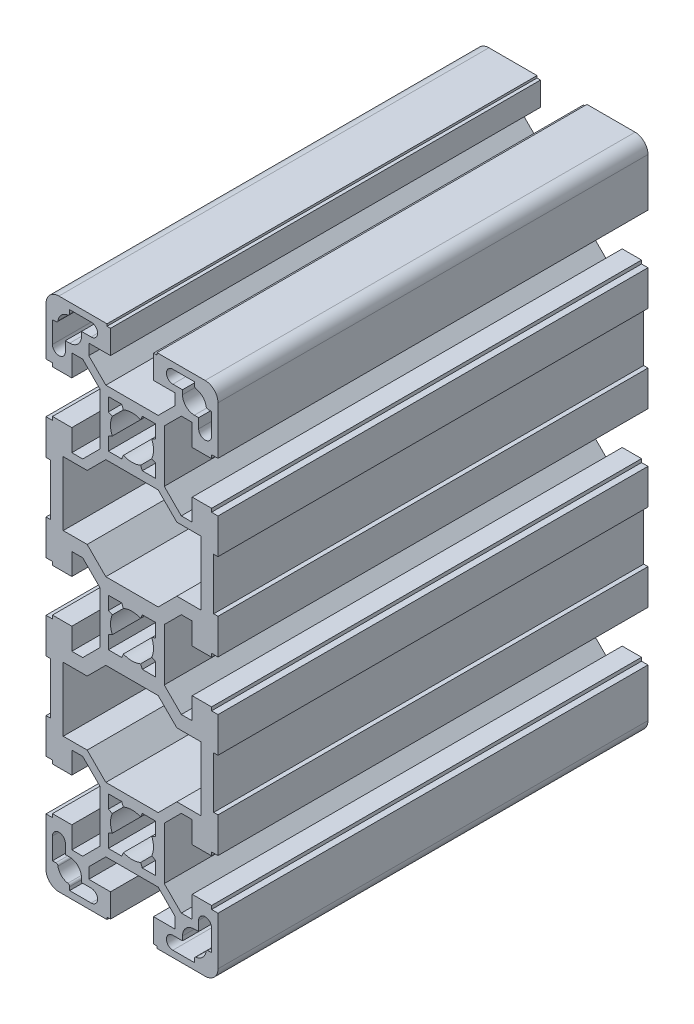
from build123d import *

# Parameters (mm, degrees)
EXTRUDE1_DEPTH = 100


with BuildPart() as part:
    # Sketch1 → Extrude1 (new body)
    with BuildSketch(Plane.XY):
        with BuildLine():
            Line((20, -57), (20, -45.8))
            Line((20, -45.8), (18.5, -45.8))
            Line((18.5, -45.8), (18.5, -45))
            Line((18.5, -45), (14, -45))
            Line((14, -45), (14, -50.05))
            Line((14, -50.05), (11.464213562, -50.05))
            Line((11.464213562, -50.05), (7.5, -46.085786438))
            Line((7.5, -46.085786438), (7.5, -33.914213562))
            Line((7.5, -33.914213562), (11.464213562, -29.95))
            Line((11.464213562, -29.95), (14, -29.95))
            Line((14, -29.95), (14, -35))
            Line((14, -35), (18.5, -35))
            Line((18.5, -35), (18.5, -34.2))
            Line((18.5, -34.2), (20, -34.2))
            Line((20, -34.2), (20, -26))
            Line((20, -26), (19, -26))
            Line((19, -26), (19, -14))
            Line((19, -14), (20, -14))
            Line((20, -14), (20, -5.8))
            Line((20, -5.8), (18.5, -5.8))
            Line((18.5, -5.8), (18.5, -5))
            Line((18.5, -5), (14, -5))
            Line((14, -5), (14, -10.05))
            Line((14, -10.05), (11.464213562, -10.05))
            Line((11.464213562, -10.05), (7.5, -6.085786438))
            Line((7.5, -6.085786438), (7.5, 6.085786438))
            Line((7.5, 6.085786438), (11.464213562, 10.05))
            Line((11.464213562, 10.05), (14, 10.05))
            Line((14, 10.05), (14, 5))
            Line((14, 5), (18.5, 5))
            Line((18.5, 5), (18.5, 5.8))
            Line((18.5, 5.8), (20, 5.8))
            Line((20, 5.8), (20, 14))
            Line((20, 14), (19, 14))
            Line((19, 14), (19, 26))
            Line((19, 26), (20, 26))
            Line((20, 26), (20, 34.2))
            Line((20, 34.2), (18.5, 34.2))
            Line((18.5, 34.2), (18.5, 35))
            Line((18.5, 35), (14, 35))
            Line((14, 35), (14, 29.95))
            Line((14, 29.95), (11.464213562, 29.95))
            Line((11.464213562, 29.95), (7.5, 33.914213562))
            Line((7.5, 33.914213562), (7.5, 46.085786438))
            Line((7.5, 46.085786438), (11.464213562, 50.05))
            Line((11.464213562, 50.05), (14, 50.05))
            Line((14, 50.05), (14, 45))
            Line((14, 45), (18.5, 45))
            Line((18.5, 45), (18.5, 45.8))
            Line((18.5, 45.8), (20, 45.8))
            Line((20, 45.8), (20, 57))
            ThreePointArc((20, 57), (19.121320344, 59.121320344), (17, 60))
            Line((17, 60), (5.805149148, 60))
            Line((5.805149148, 60), (5.805149148, 59.5))
            Line((5.805149148, 59.5), (5, 59.5))
            Line((5, 59.5), (5, 54))
            Line((5, 54), (10.05, 54))
            Line((10.05, 54), (10.05, 51.464213562))
            Line((10.05, 51.464213562), (6.085786438, 47.5))
            Line((6.085786438, 47.5), (-6.085786438, 47.5))
            Line((-6.085786438, 47.5), (-10.05, 51.464213562))
            Line((-10.05, 51.464213562), (-10.05, 54))
            Line((-10.05, 54), (-5, 54))
            Line((-5, 54), (-5, 59.5))
            Line((-5, 59.5), (-5.805149148, 59.5))
            Line((-5.805149148, 59.5), (-5.805149148, 60))
            Line((-5.805149148, 60), (-17, 60))
            ThreePointArc((-17, 60), (-19.121320344, 59.121320344), (-20, 57))
            Line((-20, 57), (-20, 45.8))
            Line((-20, 45.8), (-18.5, 45.8))
            Line((-18.5, 45.8), (-18.5, 45))
            Line((-18.5, 45), (-14, 45))
            Line((-14, 45), (-14, 50.05))
            Line((-14, 50.05), (-11.464213562, 50.05))
            Line((-11.464213562, 50.05), (-7.5, 46.085786438))
            Line((-7.5, 46.085786438), (-7.5, 33.914213562))
            Line((-7.5, 33.914213562), (-11.464213562, 29.95))
            Line((-11.464213562, 29.95), (-14, 29.95))
            Line((-14, 29.95), (-14, 35))
            Line((-14, 35), (-18.5, 35))
            Line((-18.5, 35), (-18.5, 34.2))
            Line((-18.5, 34.2), (-20, 34.2))
            Line((-20, 34.2), (-20, 26))
            Line((-20, 26), (-19, 26))
            Line((-19, 26), (-19, 14))
            Line((-19, 14), (-20, 14))
            Line((-20, 14), (-20, 5.8))
            Line((-20, 5.8), (-18.5, 5.8))
            Line((-18.5, 5.8), (-18.5, 5))
            Line((-18.5, 5), (-14, 5))
            Line((-14, 5), (-14, 10.05))
            Line((-14, 10.05), (-11.464213562, 10.05))
            Line((-11.464213562, 10.05), (-7.5, 6.085786438))
            Line((-7.5, 6.085786438), (-7.5, -6.085786438))
            Line((-7.5, -6.085786438), (-11.464213562, -10.05))
            Line((-11.464213562, -10.05), (-14, -10.05))
            Line((-14, -10.05), (-14, -5))
            Line((-14, -5), (-18.5, -5))
            Line((-18.5, -5), (-18.5, -5.8))
            Line((-18.5, -5.8), (-20, -5.8))
            Line((-20, -5.8), (-20, -14))
            Line((-20, -14), (-19, -14))
            Line((-19, -14), (-19, -26))
            Line((-19, -26), (-20, -26))
            Line((-20, -26), (-20, -34.2))
            Line((-20, -34.2), (-18.5, -34.2))
            Line((-18.5, -34.2), (-18.5, -35))
            Line((-18.5, -35), (-14, -35))
            Line((-14, -35), (-14, -29.95))
            Line((-14, -29.95), (-11.464213562, -29.95))
            Line((-11.464213562, -29.95), (-7.5, -33.914213562))
            Line((-7.5, -33.914213562), (-7.5, -46.085786438))
            Line((-7.5, -46.085786438), (-11.464213562, -50.05))
            Line((-11.464213562, -50.05), (-14, -50.05))
            Line((-14, -50.05), (-14, -45))
            Line((-14, -45), (-18.5, -45))
            Line((-18.5, -45), (-18.5, -45.8))
            Line((-18.5, -45.8), (-20, -45.8))
            Line((-20, -45.8), (-20, -57))
            ThreePointArc((-20, -57), (-19.121320344, -59.121320344), (-17, -60))
            Line((-17, -60), (-5.805149148, -60))
            Line((-5.805149148, -60), (-5.805149148, -59.5))
            Line((-5.805149148, -59.5), (-5, -59.5))
            Line((-5, -59.5), (-5, -54))
            Line((-5, -54), (-10.05, -54))
            Line((-10.05, -54), (-10.05, -51.464213562))
            Line((-10.05, -51.464213562), (-6.085786438, -47.5))
            Line((-6.085786438, -47.5), (6.085786438, -47.5))
            Line((6.085786438, -47.5), (10.05, -51.464213562))
            Line((10.05, -51.464213562), (10.05, -54))
            Line((10.05, -54), (5, -54))
            Line((5, -54), (5, -59.5))
            Line((5, -59.5), (5.805149148, -59.5))
            Line((5.805149148, -59.5), (5.805149148, -60))
            Line((5.805149148, -60), (17, -60))
            ThreePointArc((17, -60), (19.121320344, -59.121320344), (20, -57))
        make_face()
        with BuildLine():
            Line((11.75, -55.5), (11.75, -54.5))
            ThreePointArc((11.75, -54.5), (12.555456352, -52.555456352), (14.5, -51.75))
            Line((14.5, -51.75), (15.5, -51.75))
            Line((15.5, -51.75), (15.5, -49.5))
            ThreePointArc((15.5, -49.5), (17, -48), (18.5, -49.5))
            Line((18.5, -49.5), (18.5, -54.5))
            Line((18.5, -54.5), (17.711308145, -54.5))
            ThreePointArc((17.711308145, -54.5), (17.386086327, -54.620222737), (17.217260738, -54.923076923))
            ThreePointArc((17.217260738, -54.923076923), (16.444543648, -56.444543648), (14.923076923, -57.217260738))
            ThreePointArc((14.923076923, -57.217260738), (14.620222737, -57.386086327), (14.5, -57.711308145))
            Line((14.5, -57.711308145), (14.5, -58.5))
            Line((14.5, -58.5), (9.5, -58.5))
            ThreePointArc((9.5, -58.5), (8, -57), (9.5, -55.5))
            Line((9.5, -55.5), (11.75, -55.5))
        make_face(mode=Mode.SUBTRACT)
        with BuildLine():
            Line((-11.75, -54.5), (-11.75, -55.5))
            Line((-11.75, -55.5), (-9.5, -55.5))
            ThreePointArc((-9.5, -55.5), (-8, -57), (-9.5, -58.5))
            Line((-9.5, -58.5), (-14.5, -58.5))
            Line((-14.5, -58.5), (-14.5, -57.711308145))
            ThreePointArc((-14.5, -57.711308145), (-14.620222737, -57.386086327), (-14.923076923, -57.217260738))
            ThreePointArc((-14.923076923, -57.217260738), (-16.444543648, -56.444543648), (-17.217260738, -54.923076923))
            ThreePointArc((-17.217260738, -54.923076923), (-17.386086327, -54.620222737), (-17.711308145, -54.5))
            Line((-17.711308145, -54.5), (-18.5, -54.5))
            Line((-18.5, -54.5), (-18.5, -49.5))
            ThreePointArc((-18.5, -49.5), (-17, -48), (-15.5, -49.5))
            Line((-15.5, -49.5), (-15.5, -51.75))
            Line((-15.5, -51.75), (-14.5, -51.75))
            ThreePointArc((-14.5, -51.75), (-12.555456352, -52.555456352), (-11.75, -54.5))
        make_face(mode=Mode.SUBTRACT)
        Polygon((15.997425426, -28.159681355), (10.426105082, -28.159681355), (6.085786438, -32.5), (-6.085786438, -32.5), (-10.426105082, -28.159681355), (-15.997425426, -28.159681355), (-15.997425426, -13.259681355), (-10.426105082, -13.259681355), (-6.088361012, -8.921937285), (6.088361012, -8.921937285), (10.426105082, -13.259681355), (15.997425426, -13.259681355), align=None, mode=Mode.SUBTRACT)
        with BuildLine():
            Line((5.5, -42.397915762), (5.5, -45.5))
            Line((5.5, -45.5), (2.397915762, -45.5))
            Line((2.397915762, -45.5), (1.998263135, -44.583333333))
            ThreePointArc((1.998263135, -44.583333333), (0, -45), (-1.998263135, -44.583333333))
            Line((-1.998263135, -44.583333333), (-2.397915762, -45.5))
            Line((-2.397915762, -45.5), (-5.5, -45.5))
            Line((-5.5, -45.5), (-5.5, -42.397915762))
            Line((-5.5, -42.397915762), (-4.583333333, -41.998263135))
            ThreePointArc((-4.583333333, -41.998263135), (-5, -40), (-4.583333333, -38.001736865))
            Line((-4.583333333, -38.001736865), (-5.5, -37.602084238))
            Line((-5.5, -37.602084238), (-5.5, -34.5))
            Line((-5.5, -34.5), (-2.397915762, -34.5))
            Line((-2.397915762, -34.5), (-1.998263135, -35.416666667))
            ThreePointArc((-1.998263135, -35.416666667), (0, -35), (1.998263135, -35.416666667))
            Line((1.998263135, -35.416666667), (2.397915762, -34.5))
            Line((2.397915762, -34.5), (5.5, -34.5))
            Line((5.5, -34.5), (5.5, -37.602084238))
            Line((5.5, -37.602084238), (4.583333333, -38.001736865))
            ThreePointArc((4.583333333, -38.001736865), (5, -40), (4.583333333, -41.998263135))
            Line((4.583333333, -41.998263135), (5.5, -42.397915762))
        make_face(mode=Mode.SUBTRACT)
        Polygon((15.997425426, 13.259681355), (15.997425426, 28.159681355), (10.426105082, 28.159681355), (6.085786438, 32.5), (-6.085786438, 32.5), (-10.426105082, 28.159681355), (-15.997425426, 28.159681355), (-15.997425426, 13.259681355), (-10.426105082, 13.259681355), (-6.088361012, 8.921937285), (6.088361012, 8.921937285), (10.426105082, 13.259681355), align=None, mode=Mode.SUBTRACT)
        with BuildLine():
            Line((5.5, -2.397915762), (5.5, -5.5))
            Line((5.5, -5.5), (2.397915762, -5.5))
            Line((2.397915762, -5.5), (1.998263135, -4.583333333))
            ThreePointArc((1.998263135, -4.583333333), (0, -5), (-1.998263135, -4.583333333))
            Line((-1.998263135, -4.583333333), (-2.397915762, -5.5))
            Line((-2.397915762, -5.5), (-5.5, -5.5))
            Line((-5.5, -5.5), (-5.5, -2.397915762))
            Line((-5.5, -2.397915762), (-4.583333333, -1.998263135))
            ThreePointArc((-4.583333333, -1.998263135), (-5, 0), (-4.583333333, 1.998263135))
            Line((-4.583333333, 1.998263135), (-5.5, 2.397915762))
            Line((-5.5, 2.397915762), (-5.5, 5.5))
            Line((-5.5, 5.5), (-2.397915762, 5.5))
            Line((-2.397915762, 5.5), (-1.998263135, 4.583333333))
            ThreePointArc((-1.998263135, 4.583333333), (0, 5), (1.998263135, 4.583333333))
            Line((1.998263135, 4.583333333), (2.397915762, 5.5))
            Line((2.397915762, 5.5), (5.5, 5.5))
            Line((5.5, 5.5), (5.5, 2.397915762))
            Line((5.5, 2.397915762), (4.583333333, 1.998263135))
            ThreePointArc((4.583333333, 1.998263135), (5, 0), (4.583333333, -1.998263135))
            Line((4.583333333, -1.998263135), (5.5, -2.397915762))
        make_face(mode=Mode.SUBTRACT)
        with BuildLine():
            Line((18.5, 54.5), (17.711308145, 54.5))
            ThreePointArc((17.711308145, 54.5), (17.386086327, 54.620222737), (17.217260738, 54.923076923))
            ThreePointArc((17.217260738, 54.923076923), (16.444543648, 56.444543648), (14.923076923, 57.217260738))
            ThreePointArc((14.923076923, 57.217260738), (14.620222737, 57.386086327), (14.5, 57.711308145))
            Line((14.5, 57.711308145), (14.5, 58.5))
            Line((14.5, 58.5), (9.5, 58.5))
            ThreePointArc((9.5, 58.5), (8, 57), (9.5, 55.5))
            Line((9.5, 55.5), (11.75, 55.5))
            Line((11.75, 55.5), (11.75, 54.5))
            ThreePointArc((11.75, 54.5), (12.555456352, 52.555456352), (14.5, 51.75))
            Line((14.5, 51.75), (15.5, 51.75))
            Line((15.5, 51.75), (15.5, 49.5))
            ThreePointArc((15.5, 49.5), (17, 48), (18.5, 49.5))
            Line((18.5, 49.5), (18.5, 54.5))
        make_face(mode=Mode.SUBTRACT)
        with BuildLine():
            Line((2.397915762, 34.5), (5.5, 34.5))
            Line((5.5, 34.5), (5.5, 37.602084238))
            Line((5.5, 37.602084238), (4.583333333, 38.001736865))
            ThreePointArc((4.583333333, 38.001736865), (5, 40), (4.583333333, 41.998263135))
            Line((4.583333333, 41.998263135), (5.5, 42.397915762))
            Line((5.5, 42.397915762), (5.5, 45.5))
            Line((5.5, 45.5), (2.397915762, 45.5))
            Line((2.397915762, 45.5), (1.998263135, 44.583333333))
            ThreePointArc((1.998263135, 44.583333333), (0, 45), (-1.998263135, 44.583333333))
            Line((-1.998263135, 44.583333333), (-2.397915762, 45.5))
            Line((-2.397915762, 45.5), (-5.5, 45.5))
            Line((-5.5, 45.5), (-5.5, 42.397915762))
            Line((-5.5, 42.397915762), (-4.583333333, 41.998263135))
            ThreePointArc((-4.583333333, 41.998263135), (-5, 40), (-4.583333333, 38.001736865))
            Line((-4.583333333, 38.001736865), (-5.5, 37.602084238))
            Line((-5.5, 37.602084238), (-5.5, 34.5))
            Line((-5.5, 34.5), (-2.397915762, 34.5))
            Line((-2.397915762, 34.5), (-1.998263135, 35.416666667))
            ThreePointArc((-1.998263135, 35.416666667), (0, 35), (1.998263135, 35.416666667))
            Line((1.998263135, 35.416666667), (2.397915762, 34.5))
        make_face(mode=Mode.SUBTRACT)
        with BuildLine():
            Line((-17.711308145, 54.5), (-18.5, 54.5))
            Line((-18.5, 54.5), (-18.5, 49.5))
            ThreePointArc((-18.5, 49.5), (-17, 48), (-15.5, 49.5))
            Line((-15.5, 49.5), (-15.5, 51.75))
            Line((-15.5, 51.75), (-14.5, 51.75))
            ThreePointArc((-14.5, 51.75), (-12.555456352, 52.555456352), (-11.75, 54.5))
            Line((-11.75, 54.5), (-11.75, 55.5))
            Line((-11.75, 55.5), (-9.5, 55.5))
            ThreePointArc((-9.5, 55.5), (-8, 57), (-9.5, 58.5))
            Line((-9.5, 58.5), (-14.5, 58.5))
            Line((-14.5, 58.5), (-14.5, 57.711308145))
            ThreePointArc((-14.5, 57.711308145), (-14.620222737, 57.386086327), (-14.923076923, 57.217260738))
            ThreePointArc((-14.923076923, 57.217260738), (-16.444543648, 56.444543648), (-17.217260738, 54.923076923))
            ThreePointArc((-17.217260738, 54.923076923), (-17.386086327, 54.620222737), (-17.711308145, 54.5))
        make_face(mode=Mode.SUBTRACT)
    extrude(amount=-EXTRUDE1_DEPTH)


solid = part.part
